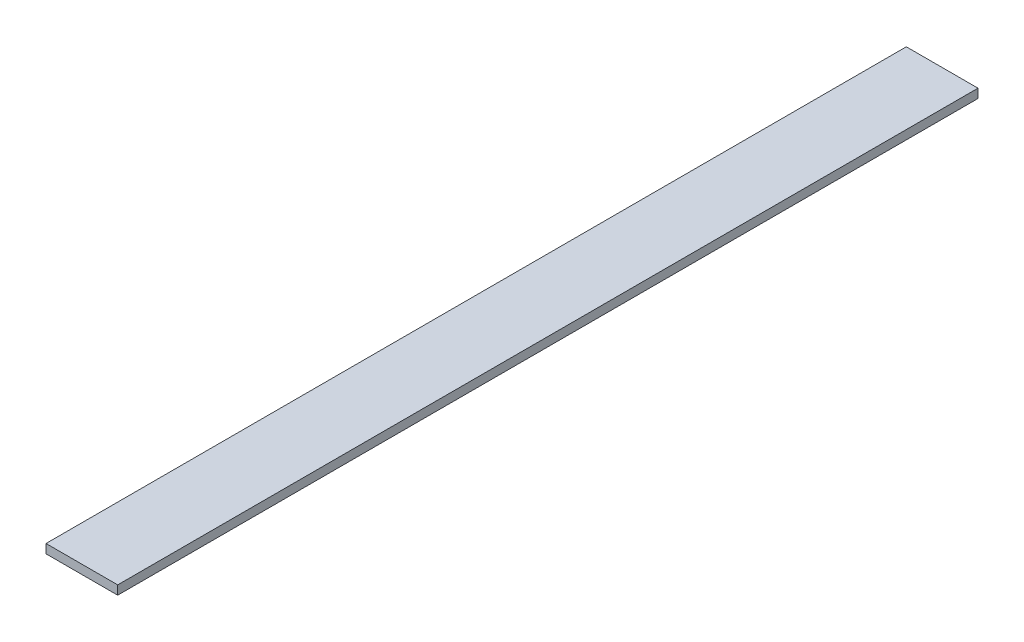
from build123d import *

# Parameters (mm, degrees)
SKETCH1_W           = 12.7
SKETCH1_H           = 152.4
BOSS_EXTRUDE1_DEPTH = 1.5875


with BuildPart() as part:
    # Sketch1 → Boss-Extrude1 (new body)
    with BuildSketch(Plane(origin=(0, 0, 0), x_dir=(1, 0, 0), z_dir=(0, 1, 0))):
        with Locations((6.35, 76.2)):
            Rectangle(SKETCH1_W, SKETCH1_H)
    extrude(amount=BOSS_EXTRUDE1_DEPTH)


solid = part.part
